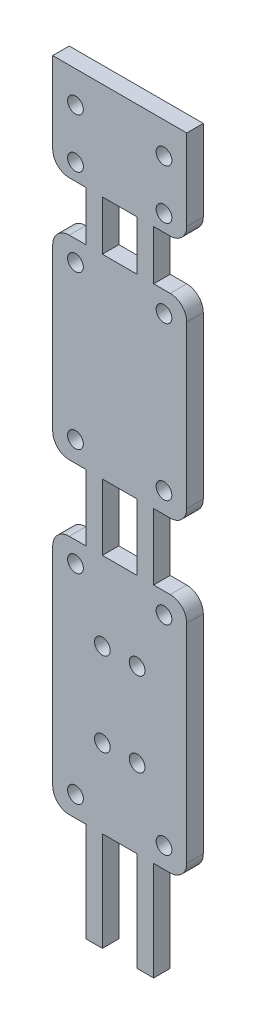
from build123d import *

# Parameters (mm, degrees)
SKETCH1_R           = 0.95
SKETCH1_W           = 4.2
SKETCH1_H           = 8
SKETCH1_H_2         = 6
BOSS_EXTRUDE1_DEPTH = 2


with BuildPart() as part:
    # Sketch1 → Boss-Extrude1 (new body)
    with BuildSketch(Plane.XY):
        with BuildLine():
            Line((4, 26), (2, 26))
            ThreePointArc((2, 26), (0.585786438, 26.585786438), (0, 28))
            Line((0, 28), (0, 53.14))
            ThreePointArc((0, 53.14), (0.585786438, 54.554213562), (2, 55.14))
            Line((2, 55.14), (4, 55.14))
            Line((4, 55.14), (4, 63.14))
            Line((4, 63.14), (2, 63.14))
            ThreePointArc((2, 63.14), (0.585786438, 63.725786438), (0, 65.14))
            Line((0, 65.14), (0, 84.665))
            ThreePointArc((0, 84.665), (0.585786438, 86.079213562), (2, 86.665))
            Line((2, 86.665), (4, 86.665))
            Line((4, 86.665), (4, 92.665))
            Line((4, 92.665), (2, 92.665))
            ThreePointArc((2, 92.665), (0.585786438, 93.250786438), (0, 94.665))
            Line((0, 94.665), (0, 104.46))
            Line((0, 104.46), (16.2, 104.46))
            Line((16.2, 104.46), (16.2, 94.665))
            ThreePointArc((16.2, 94.665), (15.614213562, 93.250786438), (14.2, 92.665))
            Line((14.2, 92.665), (12.2, 92.665))
            Line((12.2, 92.665), (12.2, 86.665))
            Line((12.2, 86.665), (14.2, 86.665))
            ThreePointArc((14.2, 86.665), (15.614213562, 86.079213562), (16.2, 84.665))
            Line((16.2, 84.665), (16.2, 65.14))
            ThreePointArc((16.2, 65.14), (15.614213562, 63.725786438), (14.2, 63.14))
            Line((14.2, 63.14), (12.2, 63.14))
            Line((12.2, 63.14), (12.2, 55.14))
            Line((12.2, 55.14), (14.2, 55.14))
            ThreePointArc((14.2, 55.14), (15.614213562, 54.554213562), (16.2, 53.14))
            Line((16.2, 53.14), (16.2, 28))
            ThreePointArc((16.2, 28), (15.614213562, 26.585786438), (14.2, 26))
            Line((14.2, 26), (12.2, 26))
            Line((12.2, 26), (12.2, 14))
            Line((12.2, 14), (10.2, 14))
            Line((10.2, 14), (10.2, 26))
            Line((10.2, 26), (6, 26))
            Line((6, 26), (6, 14))
            Line((6, 14), (4, 14))
            Line((4, 14), (4, 26))
        make_face()
        with Locations((13.45, 94.665)):
            Circle(SKETCH1_R, mode=Mode.SUBTRACT)
        with Locations((13.45, 84.165)):
            Circle(SKETCH1_R, mode=Mode.SUBTRACT)
        with Locations((13.45, 65.64)):
            Circle(SKETCH1_R, mode=Mode.SUBTRACT)
        with Locations((13.45, 52.64)):
            Circle(SKETCH1_R, mode=Mode.SUBTRACT)
        with Locations((13.45, 28.5)):
            Circle(SKETCH1_R, mode=Mode.SUBTRACT)
        with Locations((10.2, 35.5)):
            Circle(SKETCH1_R, mode=Mode.SUBTRACT)
        with Locations((10.2, 45.64)):
            Circle(SKETCH1_R, mode=Mode.SUBTRACT)
        with Locations((13.45, 100.665)):
            Circle(SKETCH1_R, mode=Mode.SUBTRACT)
        with Locations((2.75, 100.665)):
            Circle(SKETCH1_R, mode=Mode.SUBTRACT)
        with Locations((6, 45.64)):
            Circle(SKETCH1_R, mode=Mode.SUBTRACT)
        with Locations((6, 35.5)):
            Circle(SKETCH1_R, mode=Mode.SUBTRACT)
        with Locations((2.75, 28.5)):
            Circle(SKETCH1_R, mode=Mode.SUBTRACT)
        with Locations((2.75, 52.64)):
            Circle(SKETCH1_R, mode=Mode.SUBTRACT)
        with Locations((2.75, 65.64)):
            Circle(SKETCH1_R, mode=Mode.SUBTRACT)
        with Locations((2.75, 84.165)):
            Circle(SKETCH1_R, mode=Mode.SUBTRACT)
        with Locations((2.75, 94.665)):
            Circle(SKETCH1_R, mode=Mode.SUBTRACT)
        with Locations((8.1, 59.14)):
            Rectangle(SKETCH1_W, SKETCH1_H, mode=Mode.SUBTRACT)
        with Locations((8.1, 89.665)):
            Rectangle(SKETCH1_W, SKETCH1_H_2, mode=Mode.SUBTRACT)
    extrude(amount=BOSS_EXTRUDE1_DEPTH)


solid = part.part
